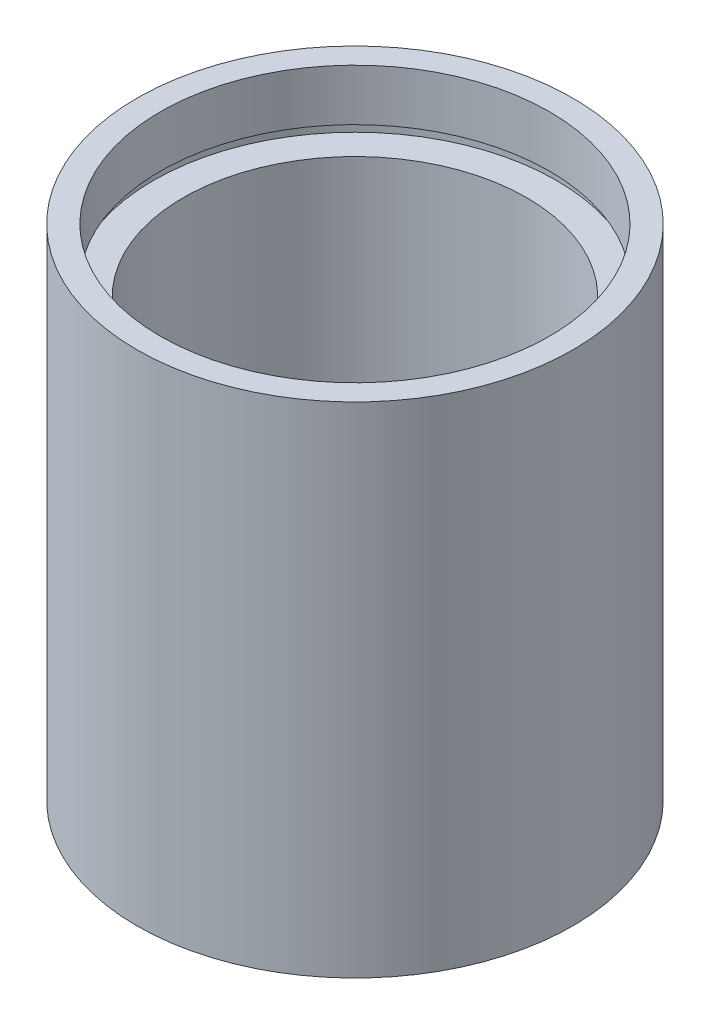
from build123d import *


with BuildPart() as part:
    # 草图1 → 旋转1 (revolve)
    with BuildSketch(Plane.XY, mode=Mode.PRIVATE) as revolve_1_sk:
        Polygon((19.05, 0), (19.05, 43.6), (17, 43.6), (17, 39.1), (17.6, 39.1), (17.6, 38.1), (15, 38.1), (15, 5.5), (17.6, 5.5), (17.6, 4.5), (17, 4.5), (17, 0), align=None)
    revolve(revolve_1_sk.sketch.rotate(Axis((0, 161.376166943, 0), (0, -1, 0)), 90), axis=Axis((0, 161.376166943, 0), (0, -1, 0)))  # turned: the seam where the file's is


solid = part.part
